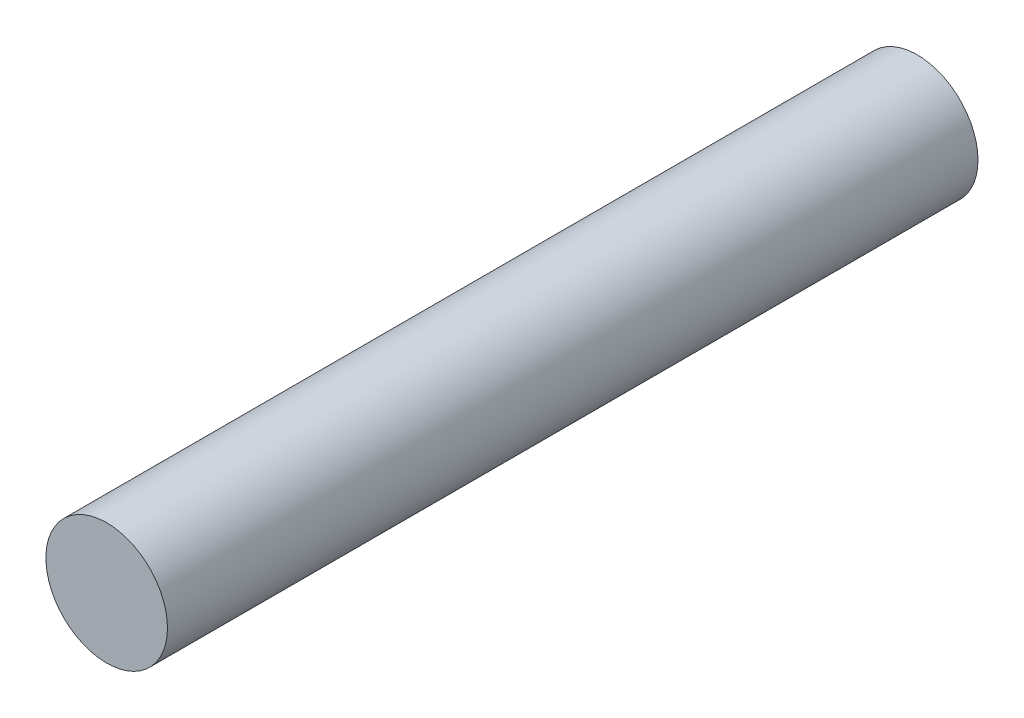
from build123d import *

# Parameters (mm, degrees)
SKETCH_1_R      = 1.5
EXTRUDE_1_DEPTH = 10


with BuildPart() as part:
    # 草圖1 → 填料-伸長1 (new body, symmetric)
    with BuildSketch(Plane.XY):
        Circle(SKETCH_1_R)
    extrude(amount=EXTRUDE_1_DEPTH, both=True)


solid = part.part
